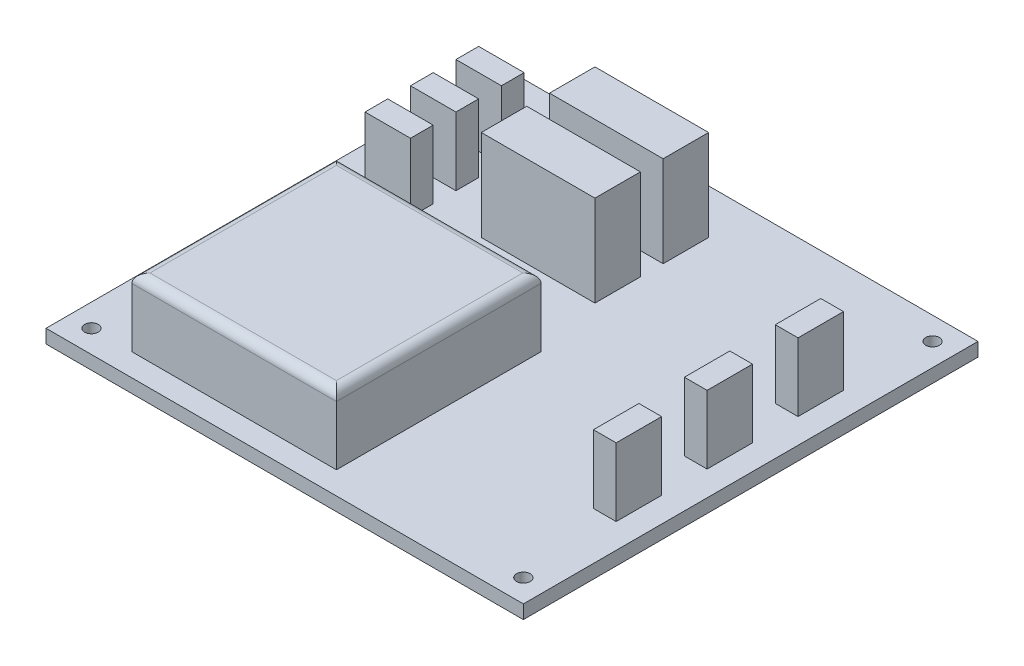
from build123d import *

# Parameters (mm, degrees)
ESQUISSE1_W      = 105
ESQUISSE1_H      = 100
ESQUISSE1_R      = 1.5
EXTRUSION1_DEPTH = 3
ESQUISSE2_W      = 45
ESQUISSE2_H      = 45
EXTRUSION2_DEPTH = 15
CONG_1_R         = 2
ESQUISSE3_W      = 5
ESQUISSE3_H      = 10
ESQUISSE3_W_2    = 10
ESQUISSE3_H_2    = 5
EXTRUSION3_DEPTH = 15
ESQUISSE4_W      = 25
ESQUISSE4_H      = 10
EXTRUSION4_DEPTH = 20


with BuildPart() as part:
    # Esquisse1 → Extrusion1 (new body)
    with BuildSketch(Plane(origin=(0, 0, 0), x_dir=(1, 0, 0), z_dir=(0, 1, 0))):
        with Locations((52.5, 50)):
            Rectangle(ESQUISSE1_W, ESQUISSE1_H)
        with Locations((5, 95)):
            Circle(ESQUISSE1_R, mode=Mode.SUBTRACT)
        with Locations((100, 95)):
            Circle(ESQUISSE1_R, mode=Mode.SUBTRACT)
        with Locations((100, 5)):
            Circle(ESQUISSE1_R, mode=Mode.SUBTRACT)
        with Locations((5, 5)):
            Circle(ESQUISSE1_R, mode=Mode.SUBTRACT)
    extrude(amount=EXTRUSION1_DEPTH)

    # Esquisse2 → Extrusion2 (add)
    with BuildSketch(Plane(origin=(0, 3, 0), x_dir=(1, 0, 0), z_dir=(0, 1, 0))):
        with Locations((36.405733266, 27.475906062)):
            Rectangle(ESQUISSE2_W, ESQUISSE2_H)
    extrude(amount=EXTRUSION2_DEPTH)

    # Congé1
    cong_1_edges = [part.edges().sort_by_distance(p)[0] for p in [
        (13.905733266, 18, -27.475906062),
        (36.405733266, 18, -4.975906062),
        (58.905733266, 18, -27.475906062),
        (36.405733266, 18, -49.975906062),
    ]]
    fillet(cong_1_edges, radius=CONG_1_R)

    # Esquisse3 → Extrusion3 (add)
    with BuildSketch(Plane(origin=(0, 3, 0), x_dir=(1, 0, 0), z_dir=(0, 1, 0))):
        with Locations((97.027568737, 70.884369428)):
            Rectangle(ESQUISSE3_W, ESQUISSE3_H)
        with Locations((13.884436985, 83.782819762)):
            Rectangle(ESQUISSE3_W_2, ESQUISSE3_H_2)
        with Locations((13.884436985, 73.782819762)):
            Rectangle(ESQUISSE3_W_2, ESQUISSE3_H_2)
        with Locations((13.884436985, 63.782819762)):
            Rectangle(ESQUISSE3_W_2, ESQUISSE3_H_2)
        with Locations((97.027568737, 50.884369428)):
            Rectangle(ESQUISSE3_W, ESQUISSE3_H)
        with Locations((97.027568737, 30.884369428)):
            Rectangle(ESQUISSE3_W, ESQUISSE3_H)
    extrude(amount=EXTRUSION3_DEPTH)

    # Esquisse4 → Extrusion4 (add)
    with BuildSketch(Plane(origin=(0, 3, 0), x_dir=(1, 0, 0), z_dir=(0, 1, 0))):
        with Locations((43.077660713, 85.165216912)):
            Rectangle(ESQUISSE4_W, ESQUISSE4_H)
        with Locations((43.077660713, 70.165216912)):
            Rectangle(ESQUISSE4_W, ESQUISSE4_H)
    extrude(amount=EXTRUSION4_DEPTH)


solid = part.part
